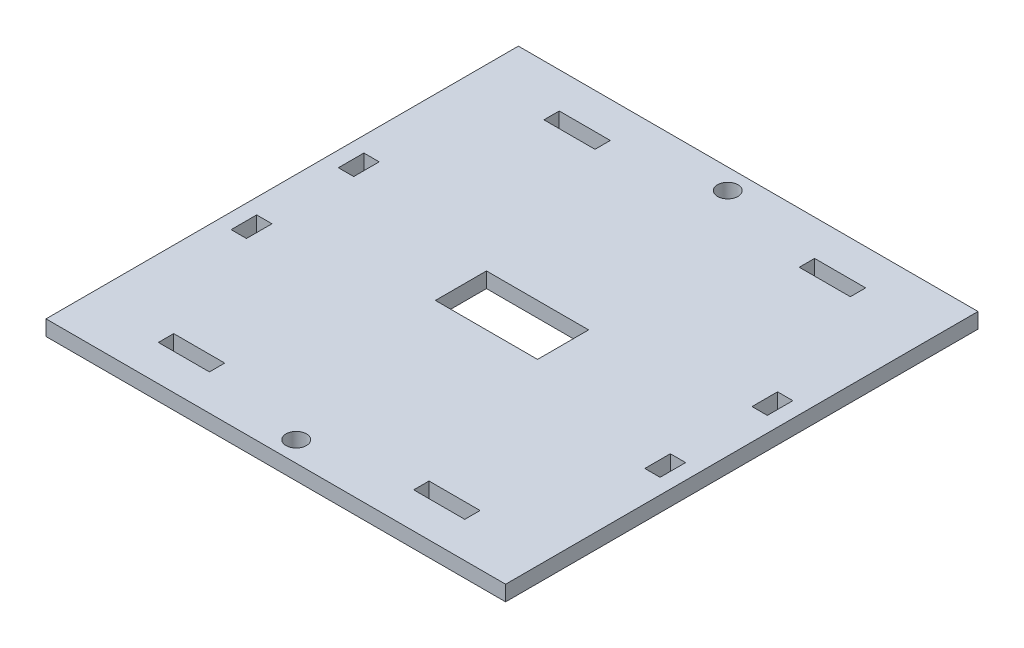
from build123d import *

# Parameters (mm, degrees)
SKETCH2_W           = 90
SKETCH2_H           = 92.5
SKETCH2_R           = 2
SKETCH2_W_2         = 10
SKETCH2_H_2         = 3
SKETCH2_W_3         = 3
SKETCH2_H_3         = 5
SKETCH2_W_4         = 20
SKETCH2_H_4         = 10
BOSS_EXTRUDE1_DEPTH = 3


with BuildPart() as part:
    # Sketch2 → Boss-Extrude1 (new body)
    with BuildSketch(Plane(origin=(0, 0, 0), x_dir=(1, 0, 0), z_dir=(0, 1, 0))):
        Rectangle(SKETCH2_W, SKETCH2_H)
        with Locations((0, -42.25)):
            Circle(SKETCH2_R, mode=Mode.SUBTRACT)
        with Locations((0, 42.25)):
            Circle(SKETCH2_R, mode=Mode.SUBTRACT)
        with Locations((-25, 37.75)):
            Rectangle(SKETCH2_W_2, SKETCH2_H_2, mode=Mode.SUBTRACT)
        with Locations((-40.5, 10.5)):
            Rectangle(SKETCH2_W_3, SKETCH2_H_3, mode=Mode.SUBTRACT)
        with Locations((25, 37.75)):
            Rectangle(SKETCH2_W_2, SKETCH2_H_2, mode=Mode.SUBTRACT)
        with Locations((25, -37.75)):
            Rectangle(SKETCH2_W_2, SKETCH2_H_2, mode=Mode.SUBTRACT)
        with Locations((-25, -37.75)):
            Rectangle(SKETCH2_W_2, SKETCH2_H_2, mode=Mode.SUBTRACT)
        with Locations((-40.5, -10.5)):
            Rectangle(SKETCH2_W_3, SKETCH2_H_3, mode=Mode.SUBTRACT)
        with Locations((40.5, 10.5)):
            Rectangle(SKETCH2_W_3, SKETCH2_H_3, mode=Mode.SUBTRACT)
        with Locations((40.5, -10.5)):
            Rectangle(SKETCH2_W_3, SKETCH2_H_3, mode=Mode.SUBTRACT)
        Rectangle(SKETCH2_W_4, SKETCH2_H_4, mode=Mode.SUBTRACT)
    extrude(amount=BOSS_EXTRUDE1_DEPTH)


solid = part.part
